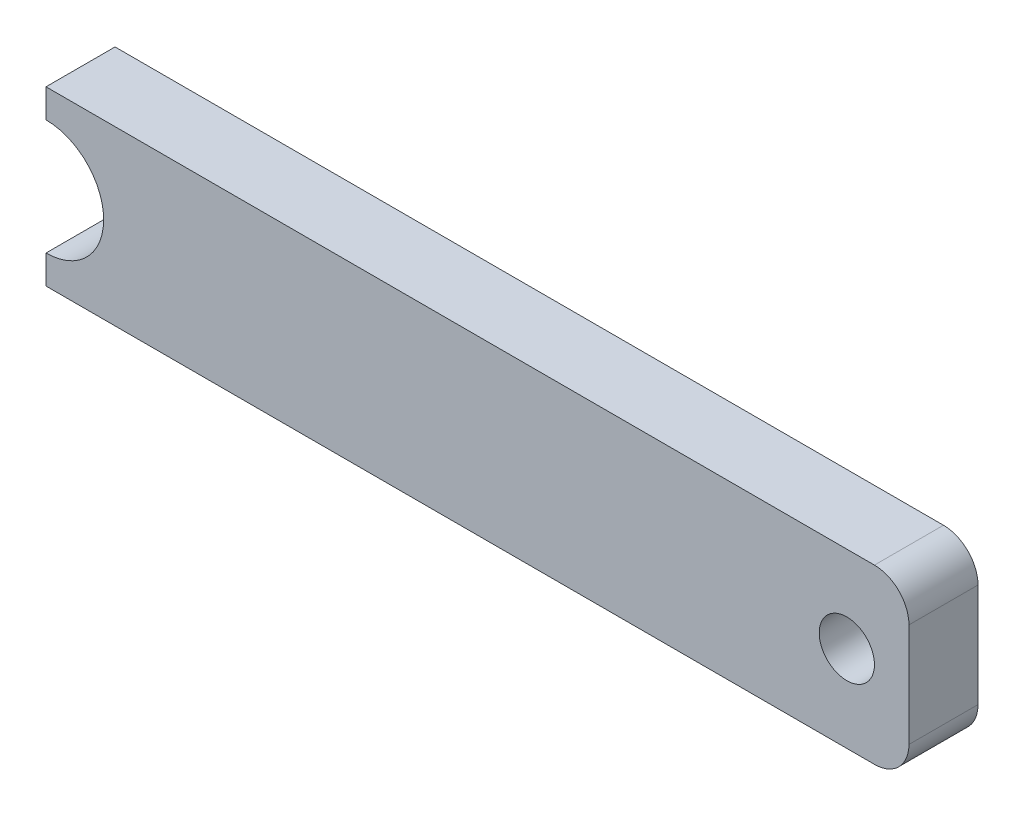
from build123d import *

# Parameters (mm, degrees)
SKETCH1_R           = 4
BOSS_EXTRUDE1_DEPTH = 10


with BuildPart() as part:
    # Sketch1 → Boss-Extrude1 (new body)
    with BuildSketch(Plane.XY):
        with BuildLine():
            Line((-62.5, 12.5), (57.5, 12.5))
            ThreePointArc((57.5, 12.5), (61.035533906, 11.035533906), (62.5, 7.5))
            Line((62.5, 7.5), (62.5, -7.5))
            ThreePointArc((62.5, -7.5), (61.035533906, -11.035533906), (57.5, -12.5))
            Line((57.5, -12.5), (-62.5, -12.5))
            Line((-62.5, -12.5), (-62.5, -8.35))
            ThreePointArc((-62.5, -8.35), (-54.15, 0), (-62.5, 8.35))
            Line((-62.5, 8.35), (-62.5, 12.5))
        make_face()
        with Locations((53.5, 0)):
            Circle(SKETCH1_R, mode=Mode.SUBTRACT)
    extrude(amount=BOSS_EXTRUDE1_DEPTH)


solid = part.part
